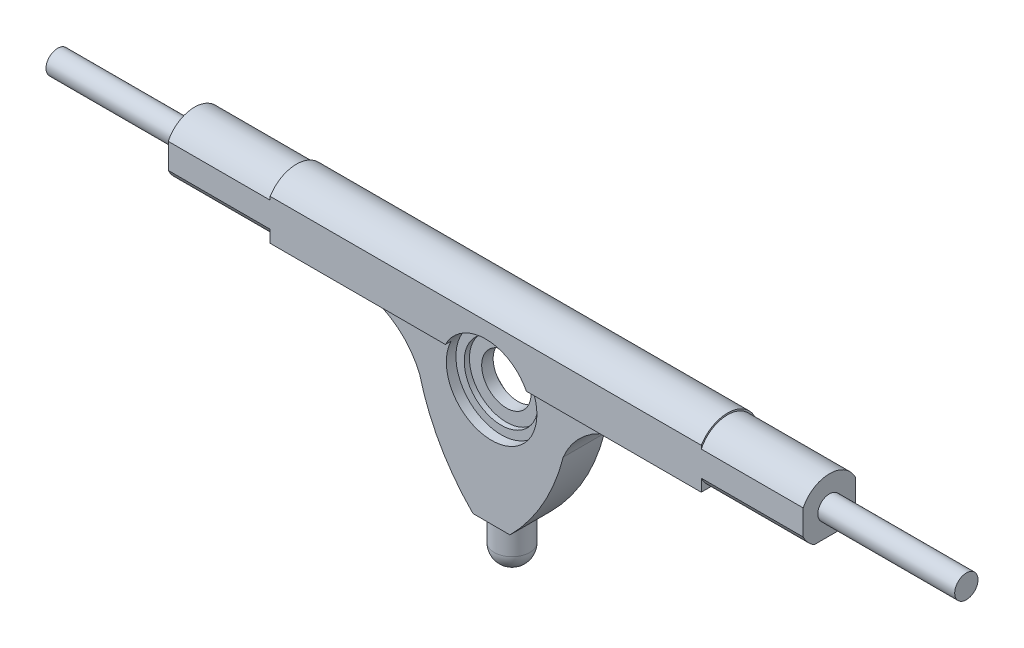
from build123d import *

# Parameters (mm, degrees)
BOSS_EXTRUDE1_DEPTH = 109
BOSS_EXTRUDE2_DEPTH = 7.0485
SKETCH11_R          = 4
BOSS_EXTRUDE3_DEPTH = 47
SKETCH12_OUTSIDE_W  = 84.63
SKETCH12_OUTSIDE_H  = 148.13
SKETCH12_OUTSIDE_R  = 10
CUT_EXTRUDE1_DEPTH  = 35


with BuildPart() as part:
    # Sketch1 → Boss-Extrude1 (new, symmetric)
    with BuildSketch(Plane(origin=(0, 0, 0), x_dir=(0, 0, -1), z_dir=(1, 0, 0))):
        with BuildLine():
            Line((-9.017, -6.985), (9.017, -6.985))
            Line((9.017, -6.985), (9.017, 6.985))
            ThreePointArc((9.017, 6.985), (0, 12.065), (-9.017, 6.985))
            Line((-9.017, 6.985), (-9.017, -6.985))
        make_face()
    extrude(amount=BOSS_EXTRUDE1_DEPTH, both=True)

    # 3DSketch1 → Boss-Extrude2 (add, symmetric)
    with BuildSketch(Plane(origin=(6.35, -54.483, 0), x_dir=(-0.707809670892054, 0.7064031920876931, 0), z_dir=(0, 0, -1))):
        with BuildLine():
            Line((0, 0), (8.98918282, -8.97132054))
            ThreePointArc((8.98918282, -8.97132054), (27.524857468, -6.428824004), (44.720760252, 0.942502247))
            ThreePointArc((44.720760252, 0.942502247), (56.955852786, 2.786694427), (68.610551817, -1.368606356))
            Line((68.610551817, -1.368606356), (7.484108639, 59.636373313))
            ThreePointArc((7.484108639, 59.636373313), (11.662583103, 47.989962481), (9.842730909, 35.751225941))
            ThreePointArc((9.842730909, 35.751225941), (2.50562293, 18.54069516), (0, 0))
        make_face()
    extrude(amount=BOSS_EXTRUDE2_DEPTH, both=True)

    # Sketch8 → Revolve2 (revolve)
    with BuildSketch(Plane.XY):
        with BuildLine():
            Line((0, -69.469), (0, -54.483))
            Line((0, -54.483), (6.096, -54.483))
            Line((6.096, -54.483), (6.096, -63.373))
            ThreePointArc((6.096, -63.373), (4.310522938, -67.683522938), (0, -69.469))
        make_face()
    revolve(axis=Axis((0, -47.134198832, 0), (0, -1, 0)))

    # Sketch10 → Cut-Revolve1 (revolve, cut)
    with BuildSketch(Plane(origin=(0, -13.977260066, 0), x_dir=(-1, 0, 0), z_dir=(0, -1, 0))):
        Polygon((-0.050623963, -9.017), (-0.050623963, 9.017), (-15.608123963, 9.017), (-15.608123963, 3.7465), (-12.750623963, 3.7465), (-12.750623963, 1.9685), (-8.534223963, 1.9685), (-8.534223963, -1.9685), (-12.750623963, -1.9685), (-12.750623963, -3.7465), (-15.608123963, -3.7465), (-15.608123963, -9.017), align=None)
    revolve(axis=Axis((0.050623963, -13.977260066, 55.769949285), (0, 0, -1)), mode=Mode.SUBTRACT)

    # Sketch11 → Boss-Extrude3 (add)
    with BuildSketch(Plane(origin=(109, 0, 0), x_dir=(0, 0, -1), z_dir=(1, 0, 0))):
        with Locations((0, 1.5224125)):
            Circle(SKETCH11_R)
    boss_extrude3 = extrude(amount=BOSS_EXTRUDE3_DEPTH)

    # Mirror1: Boss-Extrude3 across plane
    add(boss_extrude3.mirror(Plane(origin=(0, 0, 0), x_dir=(0, 0, 1), z_dir=(1, 0, 0))))

    # Sketch12 outside → Cut-Extrude1 (cut)
    with BuildSketch(Plane(origin=(109, 0, 0), x_dir=(0, 0, -1), z_dir=(1, 0, 0))):
        with Locations((0, -28.702)):
            Rectangle(SKETCH12_OUTSIDE_W, SKETCH12_OUTSIDE_H)
        with Locations((0, 1.5224125)):
            Circle(SKETCH12_OUTSIDE_R, mode=Mode.SUBTRACT)
    cut_extrude1 = extrude(amount=-CUT_EXTRUDE1_DEPTH, mode=Mode.SUBTRACT)

    # Mirror3: Cut-Extrude1 across plane
    add(cut_extrude1.mirror(Plane(origin=(0, 0, 0), x_dir=(0, 0, 1), z_dir=(1, 0, 0))), mode=Mode.SUBTRACT)


solid = part.part
